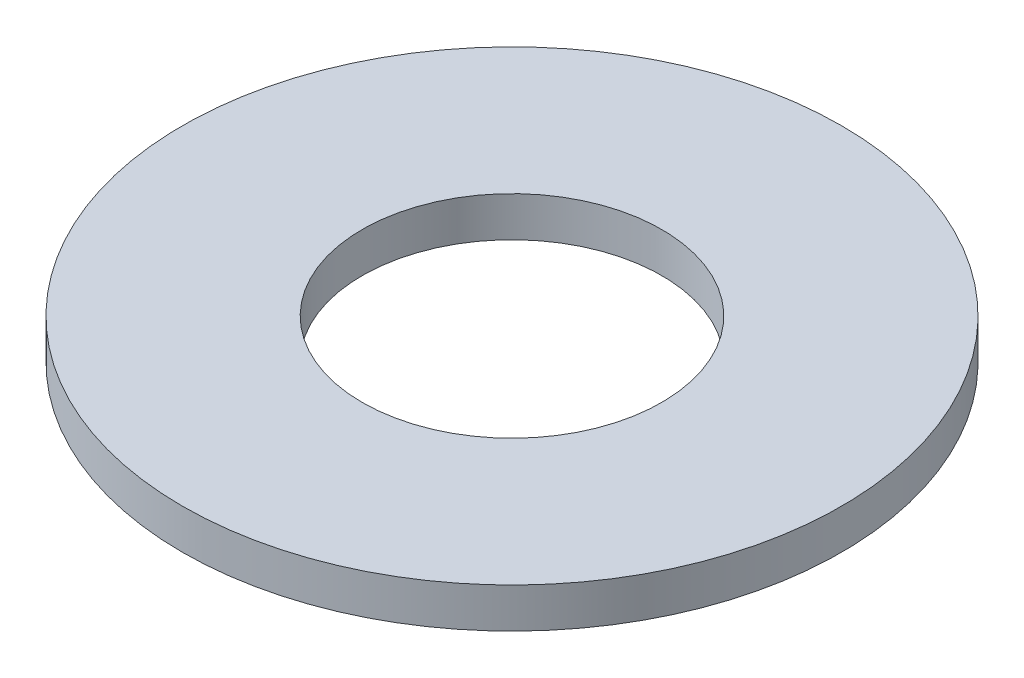
from build123d import *

# Parameters (mm, degrees)
SKETCH1_R           = 82.5
SKETCH1_R_2         = 37.5
BOSS_EXTRUDE1_DEPTH = 5


with BuildPart() as part:
    # Sketch1 → Boss-Extrude1 (new body, symmetric)
    with BuildSketch(Plane(origin=(0, 0, 0), x_dir=(1, 0, 0), z_dir=(0, 1, 0))):
        Circle(SKETCH1_R)
        Circle(SKETCH1_R_2, mode=Mode.SUBTRACT)
    extrude(amount=BOSS_EXTRUDE1_DEPTH, both=True)


solid = part.part
